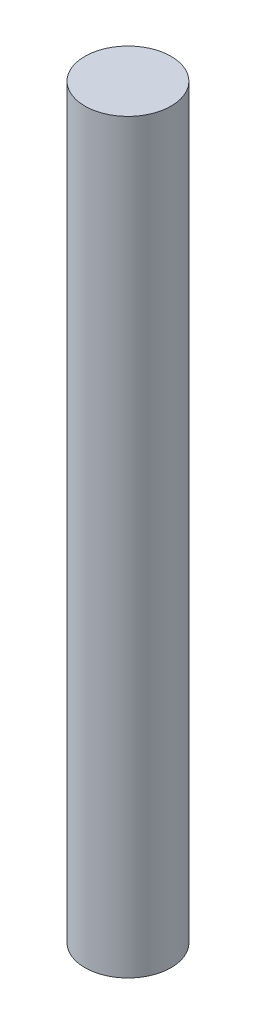
from build123d import *

# Parameters (mm, degrees)
SKETCH1_R      = 3.302
EXTRUDE1_DEPTH = 57.15


with BuildPart() as part:
    # Sketch1 → Extrude1 (new body)
    with BuildSketch(Plane(origin=(0, 0, 0), x_dir=(1, 0, 0), z_dir=(0, 1, 0))):
        Circle(SKETCH1_R)
    extrude(amount=EXTRUDE1_DEPTH)


solid = part.part
